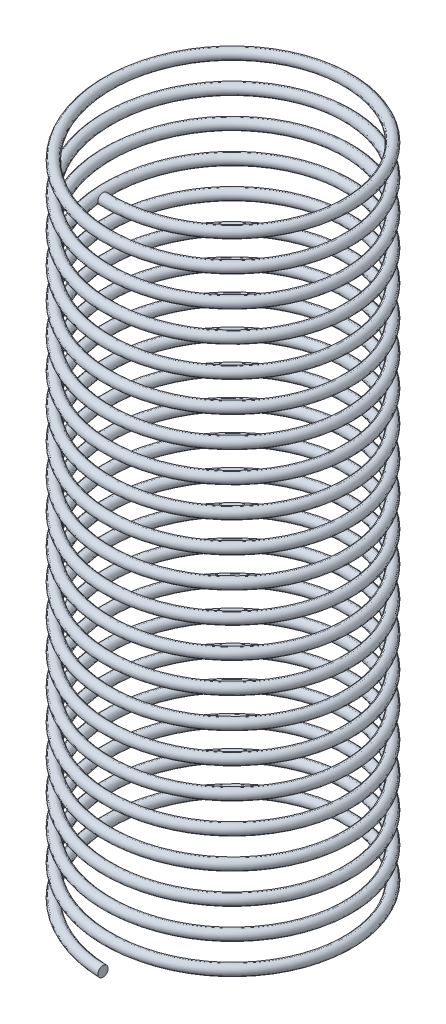
from build123d import *

# Parameters (mm, degrees)
SWEEP1_PITCH  = 0.75
SWEEP1_HEIGHT = 16.5
SWEEP1_RADIUS = 2.985
SKETCH2_R     = 0.126662285


with BuildPart() as part:
    # Sweep1: sweep along a helix
    with BuildLine() as sweep1_path:
        Helix(SWEEP1_PITCH, SWEEP1_HEIGHT, SWEEP1_RADIUS, center=(0, 0, 0), direction=(0, 1, 0), lefthand=True)
    # Sketch2 → Sweep1 (sweep)
    with BuildSketch(Plane(origin=(0, 0, 0), x_dir=(0, 0, -1), z_dir=(1, 0, 0))):
        with Locations((-2.957482425, 0)):
            Circle(SKETCH2_R)
    sweep(path=sweep1_path.line, is_frenet=True)


solid = part.part
